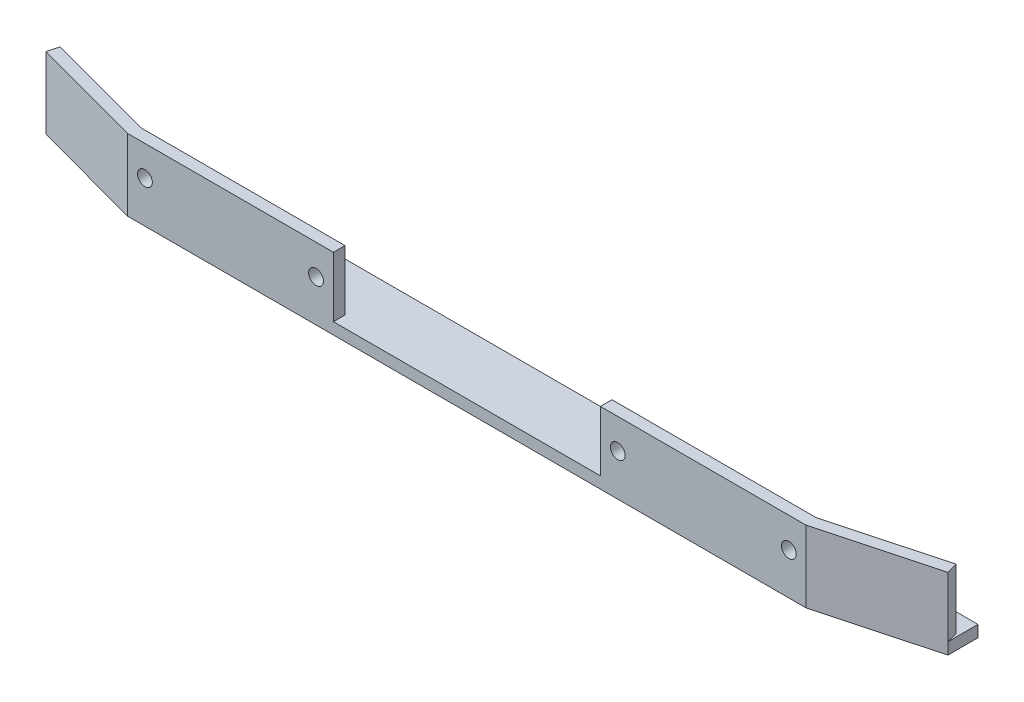
from build123d import *

# Parameters (mm, degrees)
SKETCH1_R           = 1.5
BOSS_EXTRUDE1_DEPTH = 2.5
BOSS_EXTRUDE2_DEPTH = 13
SKETCH3_R           = 1.6
CUT_EXTRUDE1_DEPTH  = 13


with BuildPart() as part:
    # Sketch1 → Boss-Extrude1 (new body)
    with BuildSketch(Plane(origin=(0, 0, 0), x_dir=(1, 0, 0), z_dir=(0, 1, 0))):
        Polygon((-58.606798355, 6.5), (-34.466582946, 0), (112.252986236, 0), (136.393201645, 6.5), (136.393201645, 13), (-58.606798355, 13), align=None)
        with Locations((-11.606798355, 9.25)):
            Circle(SKETCH1_R, mode=Mode.SUBTRACT)
        with Locations((89.393201645, 9.25)):
            Circle(SKETCH1_R, mode=Mode.SUBTRACT)
    extrude(amount=BOSS_EXTRUDE1_DEPTH)

    # Sketch2 → Boss-Extrude2 (add)
    with BuildSketch(Plane(origin=(0, 2.5, 0), x_dir=(1, 0, 0), z_dir=(0, 1, 0))):
        Polygon((-58.606798355, 6.5), (-34.466582946, 0), (10.033417054, 0), (10.033417054, 2.5), (-34.135896564, 2.5), (-57.956798355, 8.914021541), align=None)
        Polygon((136.393201645, 6.5), (112.252986236, 0), (67.752986236, 0), (67.752986236, 2.5), (111.922299855, 2.5), (135.743201645, 8.914021541), align=None)
    extrude(amount=BOSS_EXTRUDE2_DEPTH)

    # Sketch3 → Cut-Extrude1 (cut)
    with BuildSketch(Plane.XY):
        with Locations((-30.716582946, 9)):
            Circle(SKETCH3_R)
        with Locations((6.283417054, 9)):
            Circle(SKETCH3_R)
        with Locations((71.502986236, 9)):
            Circle(SKETCH3_R)
        with Locations((108.502986236, 9)):
            Circle(SKETCH3_R)
    extrude(amount=-CUT_EXTRUDE1_DEPTH, mode=Mode.SUBTRACT)


solid = part.part
